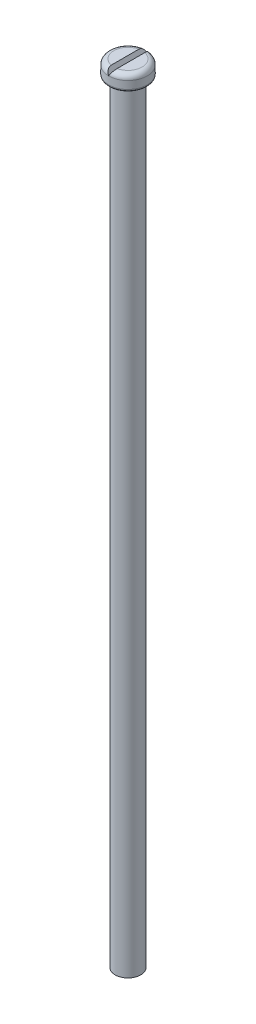
from build123d import *

# Parameters (mm, degrees)
SKETCH1_R               = 2.5
BOSS_EXTRUDE1_DEPTH     = 150
SKETCH2_R               = 3.75
BOSS_EXTRUDE2_DEPTH     = 3
FILLET1_R               = 1
CUT_EXTRUDE1_DEPTH      = 10
CUT_EXTRUDE1_DEPTH_BACK = 10
FILLET2_R               = 0.5


with BuildPart() as part:
    # Sketch1 → Boss-Extrude1 (new body)
    with BuildSketch(Plane(origin=(0, 0, 0), x_dir=(1, 0, 0), z_dir=(0, 1, 0))):
        Circle(SKETCH1_R)
    extrude(amount=BOSS_EXTRUDE1_DEPTH)

    # Sketch2 → Boss-Extrude2 (add)
    with BuildSketch(Plane(origin=(0, 150, 0), x_dir=(1, 0, 0), z_dir=(0, 1, 0))):
        Circle(SKETCH2_R)
    extrude(amount=BOSS_EXTRUDE2_DEPTH)

    # Fillet1
    fillet1_edges = [part.edges().sort_by_distance(p)[0] for p in [
        (-3.75, 153, 0),
    ]]
    fillet(fillet1_edges, radius=FILLET1_R)

    # Sketch4 → Cut-Extrude1 (cut, two sides: drawn at the far end of the back side and taken through both)
    with BuildSketch(Plane.XY.offset(-CUT_EXTRUDE1_DEPTH_BACK)):
        Polygon((0, 152), (-0.577350269, 153), (0.577350269, 153), align=None)
    extrude(amount=CUT_EXTRUDE1_DEPTH + CUT_EXTRUDE1_DEPTH_BACK, mode=Mode.SUBTRACT)

    # Fillet2
    fillet2_edges = [part.edges().sort_by_distance(p)[0] for p in [
        (-3.75, 150, 0),
    ]]
    fillet(fillet2_edges, radius=FILLET2_R)


solid = part.part
